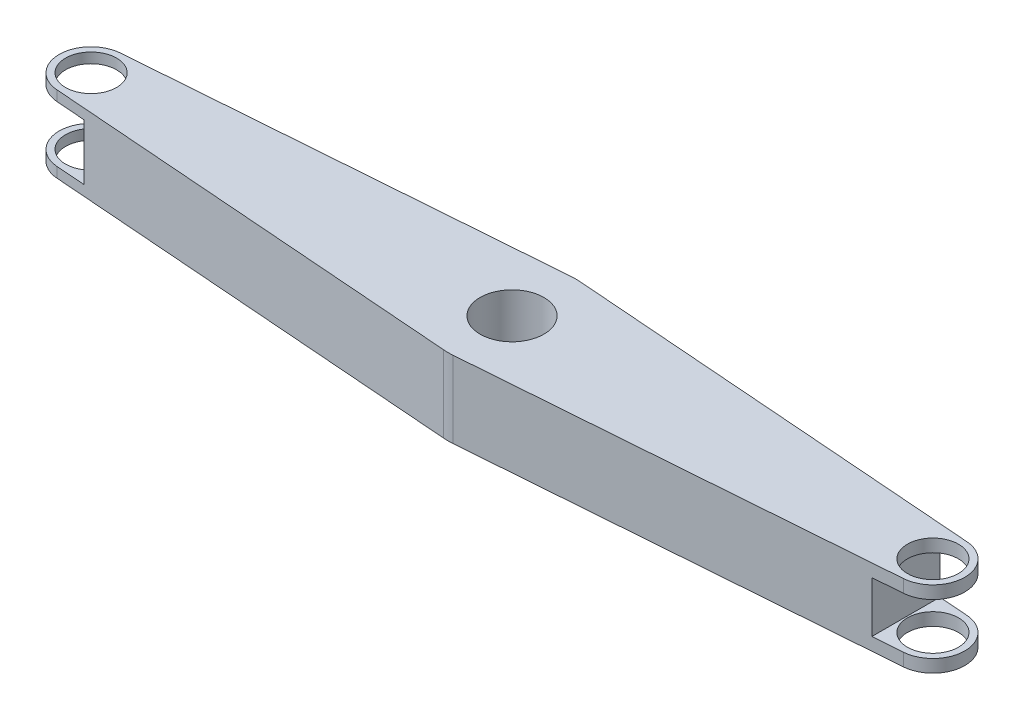
from build123d import *

# Parameters (mm, degrees)
CROQUIS1_R                 = 12.5
SALIENTE_EXTRUIR1_DEPTH    = 15
CROQUIS2_W                 = 23.106060606
CROQUIS2_H                 = 20
CROQUIS2_H_2               = 22
CORTAR_EXTRUIR1_DEPTH      = 26
CORTAR_EXTRUIR1_DEPTH_BACK = 26
CROQUIS3_R                 = 10
CORTAR_EXTRUIR2_DEPTH      = 16
CORTAR_EXTRUIR2_DEPTH_BACK = 16


with BuildPart() as part:
    # Croquis1 → Saliente-Extruir1 (new body, symmetric)
    with BuildSketch(Plane(origin=(0, 0, 0), x_dir=(1, 0, 0), z_dir=(0, 1, 0))):
        with BuildLine():
            Line((-165.946969697, 12.464078321), (-1.893939394, 24.928156642))
            ThreePointArc((-1.893939394, 24.928156642), (0, 25), (1.893939394, 24.928156642))
            Line((1.893939394, 24.928156642), (165.946969697, 12.464078321))
            ThreePointArc((165.946969697, 12.464078321), (177.5, 0), (165.946969697, -12.464078321))
            Line((165.946969697, -12.464078321), (1.893939394, -24.928156642))
            ThreePointArc((1.893939394, -24.928156642), (0, -25), (-1.893939394, -24.928156642))
            Line((-1.893939394, -24.928156642), (-165.946969697, -12.464078321))
            ThreePointArc((-165.946969697, -12.464078321), (-177.5, 0), (-165.946969697, 12.464078321))
        make_face()
        Circle(CROQUIS1_R, mode=Mode.SUBTRACT)
    extrude(amount=SALIENTE_EXTRUIR1_DEPTH, both=True)

    # Croquis2 → Cortar-Extruir1 (cut, two sides)
    with BuildSketch(Plane.XY) as cortar_extruir1_sk:
        with Locations((165.946969697, 0)):
            Rectangle(CROQUIS2_W, CROQUIS2_H)
        with Locations((-165.946969697, 0)):
            Rectangle(CROQUIS2_W, CROQUIS2_H_2)
    extrude(amount=CORTAR_EXTRUIR1_DEPTH, mode=Mode.SUBTRACT)
    extrude(cortar_extruir1_sk.sketch, amount=-CORTAR_EXTRUIR1_DEPTH_BACK, mode=Mode.SUBTRACT)

    # Croquis3 → Cortar-Extruir2 (cut, two sides)
    with BuildSketch(Plane(origin=(0, 0, 0), x_dir=(1, 0, 0), z_dir=(0, 1, 0))) as cortar_extruir2_sk:
        with Locations((-165, 0)):
            Circle(CROQUIS3_R)
        with Locations((165, 0)):
            Circle(CROQUIS3_R)
    extrude(amount=CORTAR_EXTRUIR2_DEPTH, mode=Mode.SUBTRACT)
    extrude(cortar_extruir2_sk.sketch, amount=-CORTAR_EXTRUIR2_DEPTH_BACK, mode=Mode.SUBTRACT)


solid = part.part
